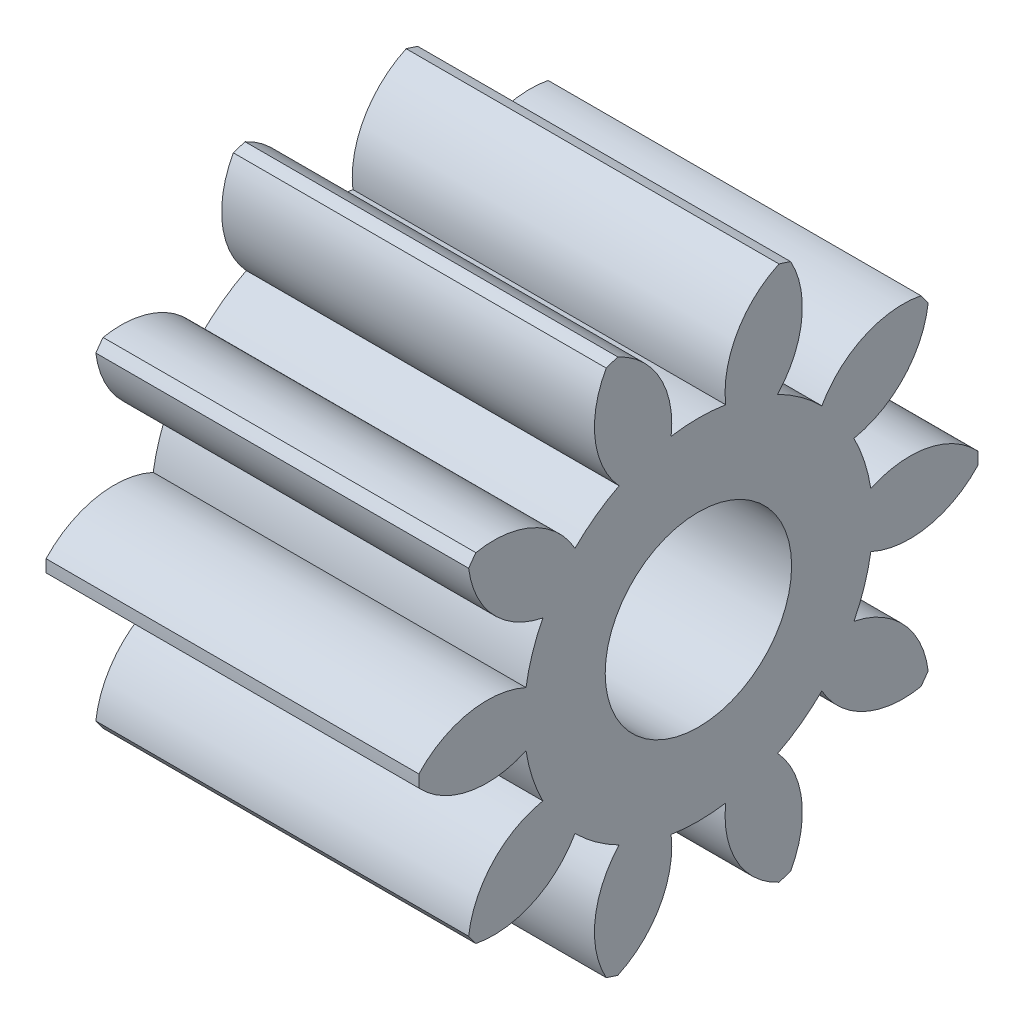
from build123d import *

# Parameters (mm, degrees)
ESQUISSE1_R        = 0.5
BOSS_EXTRU_1_DEPTH = 2


with BuildPart() as part:
    # Esquisse1 → Boss.-Extru.1 (new body)
    with BuildSketch(Plane(origin=(0, 0, 0), x_dir=(0, -1, 0), z_dir=(-1, 0, 0))):
        with BuildLine():
            ThreePointArc((-0.908086992, -1.193891961), (-0.881677878, -1.213525492), (-0.854844416, -1.232574957))
            ThreePointArc((-0.854844416, -1.232574957), (-0.575515338, -1.103091387), (-0.424999995, -0.834510188))
            ThreePointArc((-0.424999995, -0.834510188), (-0.289394415, -0.890664428), (-0.146680563, -0.924941654))
            ThreePointArc((-0.146680563, -0.924941654), (-0.18277916, -1.230699107), (-0.032905721, -1.499639028))
            ThreePointArc((-0.032905721, -1.499639028), (0, -1.5), (0.032905721, -1.499639028))
            ThreePointArc((0.032905721, -1.499639028), (0.18277916, -1.230699107), (0.146680563, -0.924941654))
            ThreePointArc((0.146680563, -0.924941654), (0.289394415, -0.890664428), (0.424999995, -0.834510188))
            ThreePointArc((0.424999995, -0.834510188), (0.575515338, -1.103091387), (0.854844416, -1.232574957))
            ThreePointArc((0.854844416, -1.232574957), (0.881677878, -1.213525492), (0.908086992, -1.193891961))
            ThreePointArc((0.908086992, -1.193891961), (0.871258232, -0.888221597), (0.662334131, -0.662076845))
            ThreePointArc((0.662334131, -0.662076845), (0.757644415, -0.550460889), (0.834345, -0.425324195))
            ThreePointArc((0.834345, -0.425324195), (1.113982538, -0.55414025), (1.416073042, -0.494709146))
            ThreePointArc((1.416073042, -0.494709146), (1.426584774, -0.463525492), (1.436409897, -0.432118744))
            ThreePointArc((1.436409897, -0.432118744), (1.226946272, -0.206473627), (0.924998573, -0.146321185))
            ThreePointArc((0.924998573, -0.146321185), (0.9365, 0), (0.924998573, 0.146321185))
            ThreePointArc((0.924998573, 0.146321185), (1.226946272, 0.206473627), (1.436409897, 0.432118744))
            ThreePointArc((1.436409897, 0.432118744), (1.426584774, 0.463525492), (1.416073042, 0.494709146))
            ThreePointArc((1.416073042, 0.494709146), (1.113982538, 0.55414025), (0.834345, 0.425324195))
            ThreePointArc((0.834345, 0.425324195), (0.757644415, 0.550460889), (0.662334131, 0.662076845))
            ThreePointArc((0.662334131, 0.662076845), (0.871258232, 0.888221597), (0.908086992, 1.193891961))
            ThreePointArc((0.908086992, 1.193891961), (0.881677878, 1.213525492), (0.854844416, 1.232574957))
            ThreePointArc((0.854844416, 1.232574957), (0.575515338, 1.103091387), (0.424999995, 0.834510188))
            ThreePointArc((0.424999995, 0.834510188), (0.289394415, 0.890664428), (0.146680563, 0.924941654))
            ThreePointArc((0.146680563, 0.924941654), (0.18277916, 1.230699107), (0.032905721, 1.499639028))
            ThreePointArc((0.032905721, 1.499639028), (0, 1.5), (-0.032905721, 1.499639028))
            ThreePointArc((-0.032905721, 1.499639028), (-0.18277916, 1.230699107), (-0.146680563, 0.924941654))
            ThreePointArc((-0.146680563, 0.924941654), (-0.289394415, 0.890664428), (-0.424999995, 0.834510188))
            ThreePointArc((-0.424999995, 0.834510188), (-0.575515338, 1.103091387), (-0.854844416, 1.232574957))
            ThreePointArc((-0.854844416, 1.232574957), (-0.881677878, 1.213525492), (-0.908086992, 1.193891961))
            ThreePointArc((-0.908086992, 1.193891961), (-0.871258232, 0.888221597), (-0.662334131, 0.662076845))
            ThreePointArc((-0.662334131, 0.662076845), (-0.757644415, 0.550460889), (-0.834345, 0.425324195))
            ThreePointArc((-0.834345, 0.425324195), (-1.113982538, 0.55414025), (-1.416073042, 0.494709146))
            ThreePointArc((-1.416073042, 0.494709146), (-1.426584774, 0.463525492), (-1.436409897, 0.432118744))
            ThreePointArc((-1.436409897, 0.432118744), (-1.226946272, 0.206473627), (-0.924998573, 0.146321185))
            ThreePointArc((-0.924998573, 0.146321185), (-0.9365, 0), (-0.924998573, -0.146321185))
            ThreePointArc((-0.924998573, -0.146321185), (-1.226946272, -0.206473627), (-1.436409897, -0.432118744))
            ThreePointArc((-1.436409897, -0.432118744), (-1.426584774, -0.463525492), (-1.416073042, -0.494709146))
            ThreePointArc((-1.416073042, -0.494709146), (-1.113982538, -0.55414025), (-0.834345, -0.425324195))
            ThreePointArc((-0.834345, -0.425324195), (-0.757644415, -0.550460889), (-0.662334131, -0.662076845))
            ThreePointArc((-0.662334131, -0.662076845), (-0.871258232, -0.888221597), (-0.908086992, -1.193891961))
        make_face()
        Circle(ESQUISSE1_R, mode=Mode.SUBTRACT)
    extrude(amount=-BOSS_EXTRU_1_DEPTH)


solid = part.part
